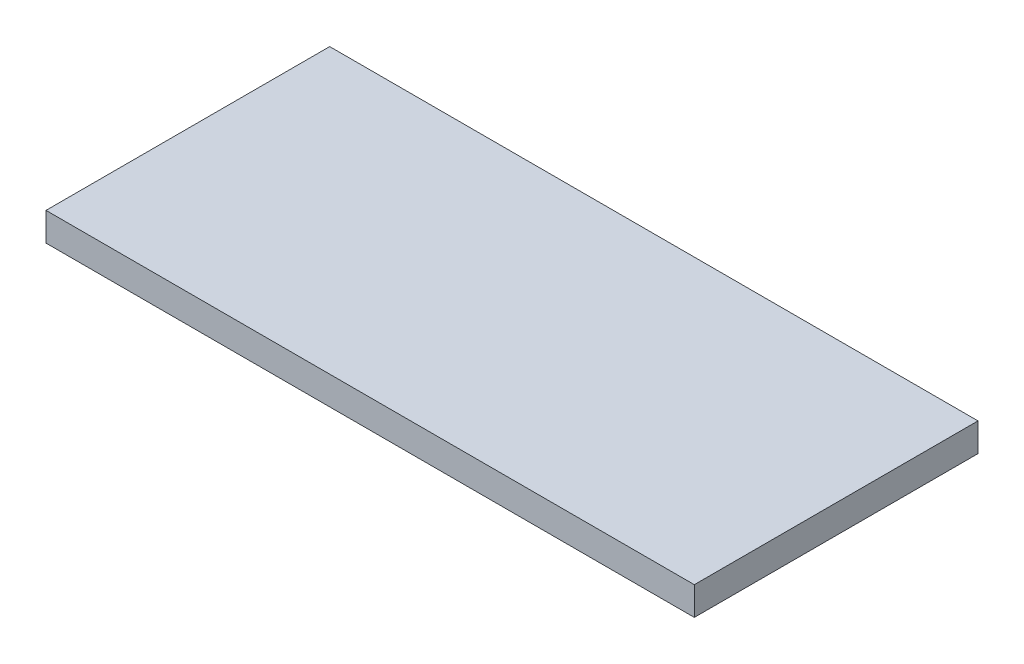
from build123d import *

# Parameters (mm, degrees)
SKETCH1_W           = 228.53
SKETCH1_H           = 100
BOSS_EXTRUDE1_DEPTH = 10


with BuildPart() as part:
    # Sketch1 → Boss-Extrude1 (new body)
    with BuildSketch(Plane(origin=(0, 0, 0), x_dir=(1, 0, 0), z_dir=(0, 1, 0))):
        Rectangle(SKETCH1_W, SKETCH1_H)
    extrude(amount=BOSS_EXTRUDE1_DEPTH)


solid = part.part
